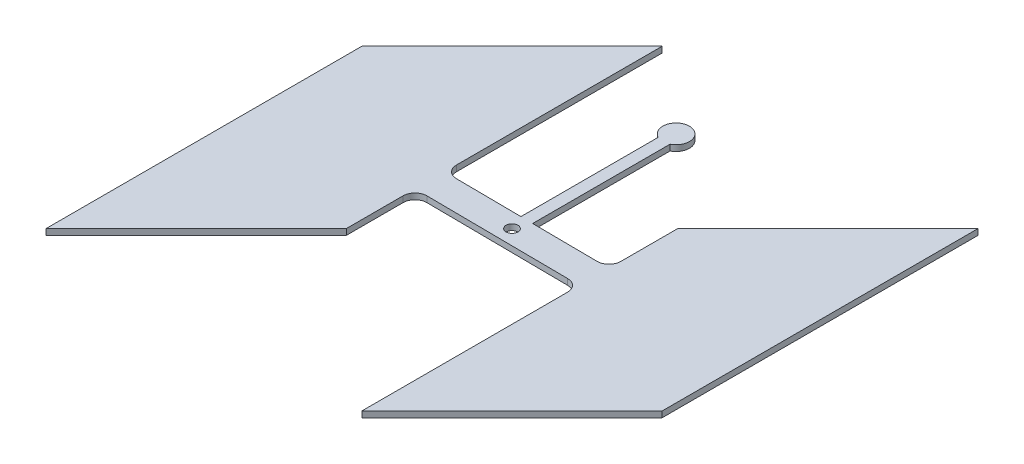
from build123d import *

# Parameters (mm, degrees)
SKETCH1_R           = 12.7
BOSS_EXTRUDE1_DEPTH = 12.7


with BuildPart() as part:
    # Sketch1 → Boss-Extrude1 (new body)
    with BuildSketch(Plane(origin=(0, 0, 0), x_dir=(1, 0, 0), z_dir=(0, 1, 0))):
        with BuildLine():
            ThreePointArc((-177.79300078, -55.798766176), (-170.27365382, -37.758748247), (-152.16762701, -30.399766064))
            Line((-152.16762701, -30.399766064), (152.618374551, -33.104233568))
            ThreePointArc((152.618374551, -33.104233568), (170.43301871, -40.622580641), (177.79300078, -58.50323368))
            Line((177.79300078, -58.50323368), (177.79300078, -500))
            Line((177.79300078, -500), (500, -177.79300078))
            Line((500, -177.79300078), (500, 500))
            Line((500, 500), (177.79300078, 177.79300078))
            Line((177.79300078, 177.79300078), (177.79300078, 55.798766176))
            ThreePointArc((177.79300078, 55.798766176), (170.27365382, 37.758748247), (152.16762701, 30.399766064))
            Line((152.16762701, 30.399766064), (12.711649925, 31.637205305))
            Line((12.711649925, 31.637205305), (12.711649925, 326.507694892))
            ThreePointArc((12.711649925, 326.507694892), (0, 380.747448982), (-12.711649925, 326.507694892))
            Line((-12.711649925, 326.507694892), (-12.711649925, 31.862794695))
            Line((-12.711649925, 31.862794695), (-152.618374551, 33.104233568))
            ThreePointArc((-152.618374551, 33.104233568), (-170.43301871, 40.62258064), (-177.79300078, 58.50323368))
            Line((-177.79300078, 58.50323368), (-177.79300078, 500))
            Line((-177.79300078, 500), (-500, 177.79300078))
            Line((-500, 177.79300078), (-500, -500))
            Line((-500, -500), (-177.79300078, -177.79300078))
            Line((-177.79300078, -177.79300078), (-177.79300078, -55.798766176))
        make_face()
        Circle(SKETCH1_R, mode=Mode.SUBTRACT)
    extrude(amount=BOSS_EXTRUDE1_DEPTH)


solid = part.part
